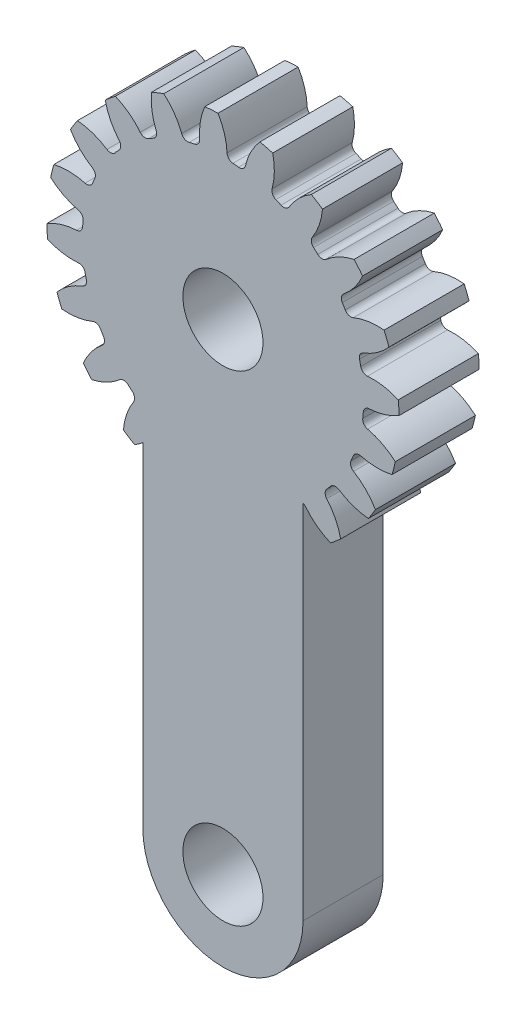
from build123d import *

# Parameters (mm, degrees)
SKETCH3_R           = 27.94
GEARBODY_DEPTH      = 12.7
TOOTHCUT_DEPTH      = 13.7
CIRPATTERN1_COUNT   = 20
BOREDIA_R           = 6.35
BORE_DEPTH          = 12700
SKETCH4_R           = 6.35
BOSS_EXTRUDE1_DEPTH = 12.7


with BuildPart() as part:
    # Sketch3 → gearBody (new body)
    with BuildSketch(Plane.XY):
        Circle(SKETCH3_R)
    extrude(amount=GEARBODY_DEPTH)

    # Sketch2 → toothCut (cut, through all)
    with BuildSketch(Plane.XY):
        with BuildLine():
            ThreePointArc((22.161994813, -2.487872048), (22.207832173, -2.038556256), (22.244560977, -1.58840435))
            ThreePointArc((22.244560977, -1.58840435), (22.544698475, -0.941259068), (23.198766614, -0.656523398))
            ThreePointArc((23.198766614, -0.656523398), (27.638401864, 0.614170289), (31.045266607, 3.731588487))
            ThreePointArc((31.045266607, 3.731588487), (31.137815759, -2.858279396), (29.847095445, -9.321170787))
            ThreePointArc((29.847095445, -9.321170787), (27.064706273, -5.635613286), (22.930600611, -3.577897568))
            ThreePointArc((22.930600611, -3.577897568), (22.339300546, -3.17884398), (22.161994813, -2.487872048))
        make_face()
    toothcut = extrude(amount=TOOTHCUT_DEPTH, mode=Mode.SUBTRACT)

    # CirPattern1: toothCut ×20 about axis
    cirpattern1_axis = Axis((0, 0, 0), (0, 0, 1))
    for i in range(1, CIRPATTERN1_COUNT):
        add(toothcut.rotate(cirpattern1_axis, i * 360 / CIRPATTERN1_COUNT), mode=Mode.SUBTRACT)

    # boreDia → bore (cut, symmetric)
    with BuildSketch(Plane.XY):
        Circle(BOREDIA_R)
    extrude(amount=BORE_DEPTH, both=True, mode=Mode.SUBTRACT)

    # Sketch4 → Boss-Extrude1 (add)
    with BuildSketch(Plane.XY):
        with BuildLine():
            Line((-12.7, -18.331762639), (-12.7, -76.2))
            ThreePointArc((-12.7, -76.2), (0, -88.9), (12.7, -76.2))
            Line((12.7, -76.2), (12.7, -18.331762639))
            ThreePointArc((12.7, -18.331762639), (0, -22.3012), (-12.7, -18.331762639))
        make_face()
        with Locations((0, -76.2)):
            Circle(SKETCH4_R, mode=Mode.SUBTRACT)
    extrude(amount=BOSS_EXTRUDE1_DEPTH)


solid = part.part
